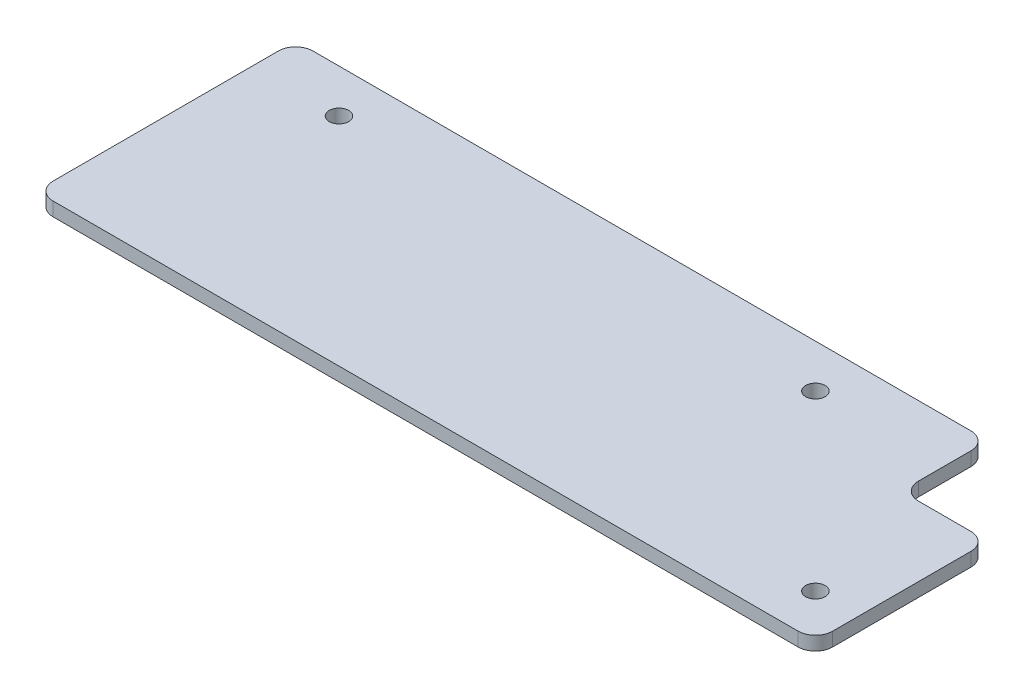
from build123d import *

# Parameters (mm, degrees)
SKETCH1_W               = 180
SKETCH1_H               = 60
BOSS_EXTRUDE1_DEPTH     = 3.175
SKETCH5_W               = 20.1
SKETCH5_H               = 20.1
CUT_EXTRUDE1_DEPTH      = 1
CUT_EXTRUDE1_DEPTH_BACK = 4.175
M4_CLEARANCE_HOLE2_D    = 4.5
FILLET2_R               = 4


with BuildPart() as part:
    # Sketch1 → Boss-Extrude1 (new body)
    with BuildSketch(Plane(origin=(0, 0, 0), x_dir=(1, 0, 0), z_dir=(0, 1, 0))):
        Rectangle(SKETCH1_W, SKETCH1_H)
    extrude(amount=BOSS_EXTRUDE1_DEPTH)

    # Sketch5 → Cut-Extrude1 (cut, two sides)
    with BuildSketch(Plane(origin=(0, 3.175, 0), x_dir=(1, 0, 0), z_dir=(0, 1, 0))) as cut_extrude1_sk:
        with Locations((79.95, 19.95)):
            Rectangle(SKETCH5_W, SKETCH5_H)
    extrude(amount=CUT_EXTRUDE1_DEPTH, mode=Mode.SUBTRACT)
    extrude(cut_extrude1_sk.sketch, amount=-CUT_EXTRUDE1_DEPTH_BACK, mode=Mode.SUBTRACT)

    # M4 Clearance Hole2 (through all)
    with Locations(Plane(origin=(0, 3.175, 0), x_dir=(1, 0, 0), z_dir=(0, 1, 0))):
        with Locations((-70, 20), (40, 20), (80, -20)):
            Hole(M4_CLEARANCE_HOLE2_D / 2)

    # Fillet2
    fillet2_edges = [part.edges().sort_by_distance(p)[0] for p in [
        (69.9, 1.5875, -9.9),
        (69.9, 1.5875, -30),
        (90, 1.5875, -9.9),
        (-90, 1.5875, -30),
        (90, 1.5875, 30),
        (-90, 1.5875, 30),
    ]]
    fillet(fillet2_edges, radius=FILLET2_R)


solid = part.part
